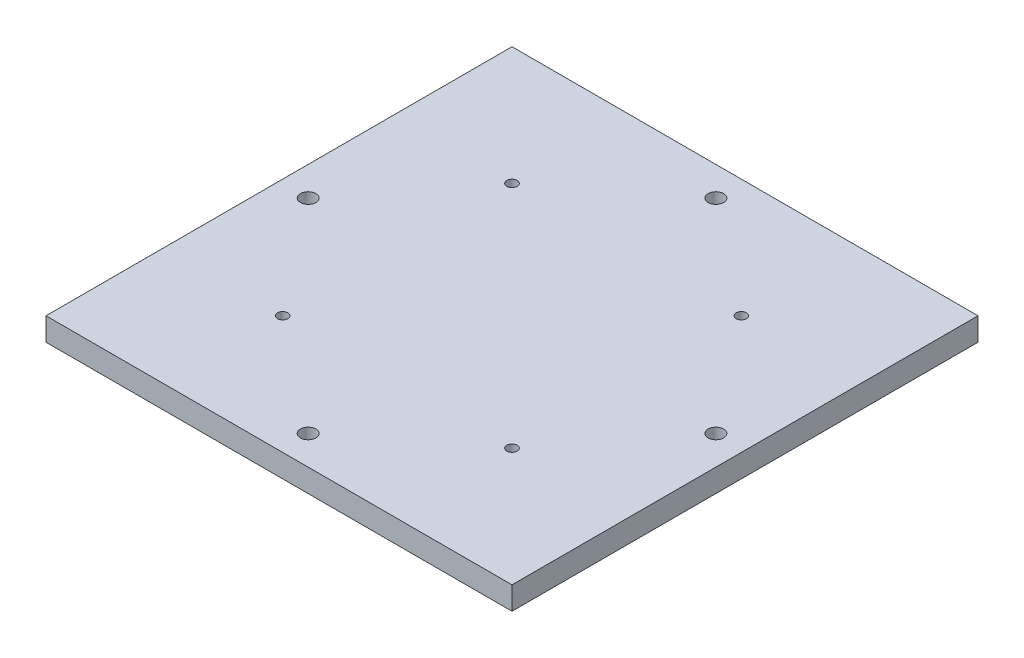
from build123d import *

# Parameters (mm, degrees)
SKETCH1_W           = 203.2
SKETCH1_H           = 203.2
SKETCH1_W_2         = 115
SKETCH1_H_2         = 115
SKETCH1_R           = 2.25
BOSS_EXTRUDE1_DEPTH = 10
SKETCH4_R           = 3.38
CUT_EXTRUDE1_DEPTH  = 11


with BuildPart() as part:
    # Sketch1 → Boss-Extrude1 (new body)
    with BuildSketch(Plane(origin=(0, 0, 0), x_dir=(1, 0, 0), z_dir=(0, 1, 0))):
        with Locations((101.6, 101.6)):
            Rectangle(SKETCH1_W, SKETCH1_H)
        with Locations((101.6, 101.6)):
            Rectangle(SKETCH1_W_2, SKETCH1_H_2, mode=Mode.SUBTRACT)
        with Locations((101.6, 101.6)):
            Rectangle(SKETCH1_W_2, SKETCH1_H_2)
        with Locations((51.6, 151.6)):
            Circle(SKETCH1_R, mode=Mode.SUBTRACT)
        with Locations((151.6, 151.6)):
            Circle(SKETCH1_R, mode=Mode.SUBTRACT)
        with Locations((151.6, 51.6)):
            Circle(SKETCH1_R, mode=Mode.SUBTRACT)
        with Locations((51.6, 51.6)):
            Circle(SKETCH1_R, mode=Mode.SUBTRACT)
    extrude(amount=BOSS_EXTRUDE1_DEPTH)

    # Sketch4 → Cut-Extrude1 (cut, through all)
    with BuildSketch(Plane(origin=(0, 10, 0), x_dir=(1, 0, 0), z_dir=(0, 1, 0))):
        with Locations((12.7, 101.6)):
            Circle(SKETCH4_R)
        with Locations((190.5, 101.6)):
            Circle(SKETCH4_R)
        with Locations((101.6, 190.5)):
            Circle(SKETCH4_R)
        with Locations((101.6, 12.7)):
            Circle(SKETCH4_R)
    extrude(amount=-CUT_EXTRUDE1_DEPTH, mode=Mode.SUBTRACT)


solid = part.part
